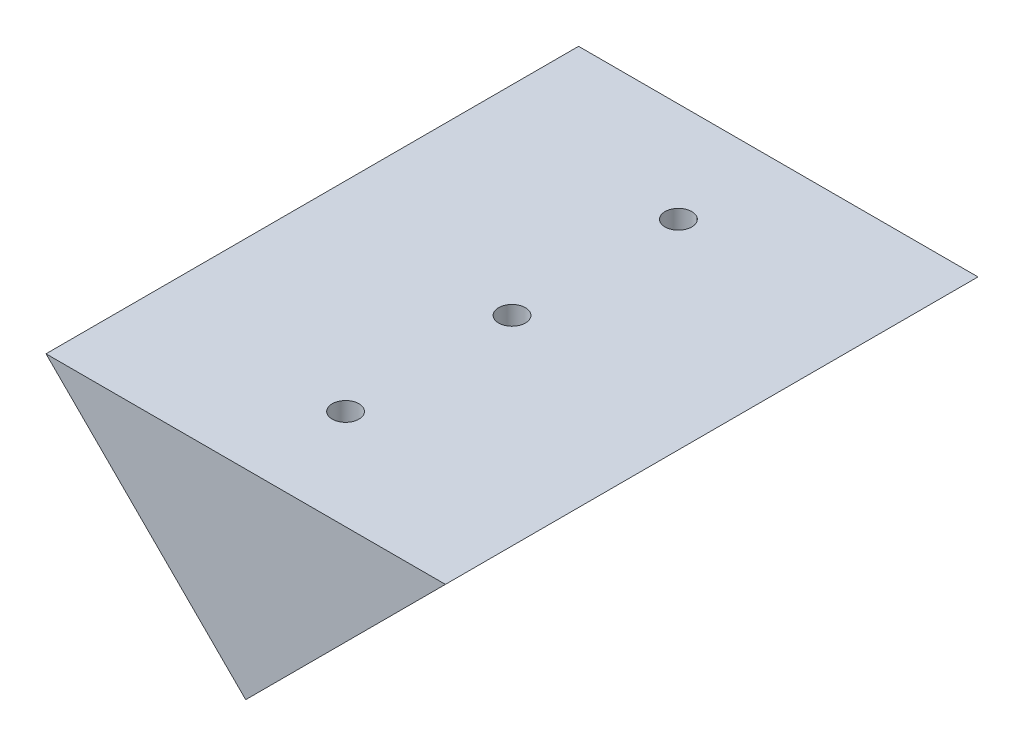
from build123d import *

# Parameters (mm, degrees)
MAIN_EXTRUDE_DEPTH        = 101.6
MOUNTING_HOLES_D          = 5.1054
MOUNTING_HOLES_DEPTH      = 16.51
MOUNTING_HOLES_TIP        = 1.533816902
BEARING_MOUNT_LEFT_D      = 5.1054
BEARING_MOUNT_LEFT_DEPTH  = 12.7
BEARING_MOUNT_LEFT_TIP    = 1.533816902
BEARING_MOUNT_RIGHT_D     = 5.1054
BEARING_MOUNT_RIGHT_DEPTH = 16.51
BEARING_MOUNT_RIGHT_TIP   = 1.533816902


with BuildPart() as part:
    # Sketch2 → Main extrude (new body)
    with BuildSketch(Plane.XY):
        Polygon((-91.469223626, 25.4), (-53.369223626, -12.7), (-15.269223626, 25.4), align=None)
    extrude(amount=MAIN_EXTRUDE_DEPTH)

    # Mounting holes
    with Locations(Plane(origin=(0, 25.4, 0), x_dir=(1, 0, 0), z_dir=(0, 1, 0))):
        with Locations((-53.369223626, -19.05), (-53.369223626, -82.55), (-53.369223626, -50.8)):
            Hole(MOUNTING_HOLES_D / 2, depth=MOUNTING_HOLES_DEPTH)
            with Locations((0, 0, -(MOUNTING_HOLES_DEPTH + MOUNTING_HOLES_TIP / 2))):  # 118° drill point
                Cone(0, MOUNTING_HOLES_D / 2, MOUNTING_HOLES_TIP, mode=Mode.SUBTRACT)

    # Bearing mount left
    with Locations(Plane(origin=(-20.334611813, 20.334611813, 0), x_dir=(-0.707106781, -0.707106781, 0), z_dir=(0.707106781, -0.707106781, 0))):
        with Locations((21.317996054, -12.7), (21.317996054, -88.9)):
            Hole(BEARING_MOUNT_LEFT_D / 2, depth=BEARING_MOUNT_LEFT_DEPTH)
            with Locations((0, 0, -(BEARING_MOUNT_LEFT_DEPTH + BEARING_MOUNT_LEFT_TIP / 2))):  # 118° drill point
                Cone(0, BEARING_MOUNT_LEFT_D / 2, BEARING_MOUNT_LEFT_TIP, mode=Mode.SUBTRACT)

    # Bearing mount right
    with Locations(Plane(origin=(-33.034611813, -33.034611813, 0), x_dir=(-0.707106781, 0.707106781, 0), z_dir=(-0.707106781, -0.707106781, 0))):
        with Locations((54.157483812, -82.55), (54.157483812, -19.05)):
            Hole(BEARING_MOUNT_RIGHT_D / 2, depth=BEARING_MOUNT_RIGHT_DEPTH)
            with Locations((0, 0, -(BEARING_MOUNT_RIGHT_DEPTH + BEARING_MOUNT_RIGHT_TIP / 2))):  # 118° drill point
                Cone(0, BEARING_MOUNT_RIGHT_D / 2, BEARING_MOUNT_RIGHT_TIP, mode=Mode.SUBTRACT)


solid = part.part
